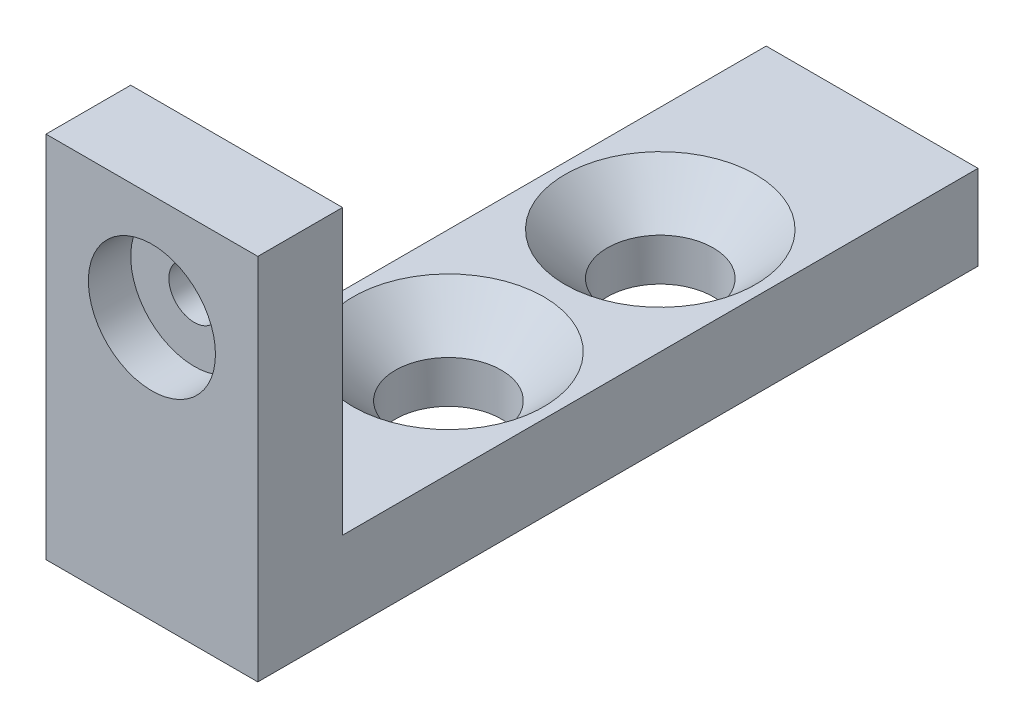
from build123d import *

# Parameters (mm, degrees)
SKETCH1_W           = 5
SKETCH1_H           = 8.7
BOSS_EXTRUDE2_DEPTH = 2
SKETCH2_R           = 1.5
CUT_EXTRUDE1_DEPTH  = 1
SKETCH3_R           = 0.6
CUT_EXTRUDE2_DEPTH  = 1
SKETCH4_W           = 5
SKETCH4_H           = 2
BOSS_EXTRUDE4_DEPTH = 15
SKETCH6_R           = 1.25
CUT_EXTRUDE4_DEPTH  = 2
CHAMFER1_SIZE       = 1


with BuildPart() as part:
    # Sketch1 → Boss-Extrude2 (new body)
    with BuildSketch(Plane.XY):
        with Locations((0, -1.85)):
            Rectangle(SKETCH1_W, SKETCH1_H)
    extrude(amount=BOSS_EXTRUDE2_DEPTH)

    # Sketch2 → Cut-Extrude1 (cut)
    with BuildSketch(Plane.XY.offset(2)):
        Circle(SKETCH2_R)
    extrude(amount=-CUT_EXTRUDE1_DEPTH, mode=Mode.SUBTRACT)

    # Sketch3 → Cut-Extrude2 (cut)
    with BuildSketch(Plane.XY.offset(1)):
        Circle(SKETCH3_R)
    extrude(amount=-CUT_EXTRUDE2_DEPTH, mode=Mode.SUBTRACT)

    # Sketch4 → Boss-Extrude4 (add)
    with BuildSketch(Plane(origin=(0, 0, 0), x_dir=(-1, 0, 0), z_dir=(0, 0, -1))):
        with Locations((0, -5.2)):
            Rectangle(SKETCH4_W, SKETCH4_H)
    extrude(amount=BOSS_EXTRUDE4_DEPTH)

    # Sketch6 → Cut-Extrude4 (cut)
    with BuildSketch(Plane(origin=(0, -4.2, 0), x_dir=(1, 0, 0), z_dir=(0, 1, 0))):
        with Locations((0, 10)):
            Circle(SKETCH6_R)
        with Locations((0, 5)):
            Circle(SKETCH6_R)
    extrude(amount=-CUT_EXTRUDE4_DEPTH, mode=Mode.SUBTRACT)

    # Chamfer1
    chamfer1_edges = [part.edges().sort_by_distance(p)[0] for p in [
        (-1.25, -4.2, -10),
        (-1.25, -4.2, -5),
    ]]
    chamfer(chamfer1_edges, length=CHAMFER1_SIZE)


solid = part.part
